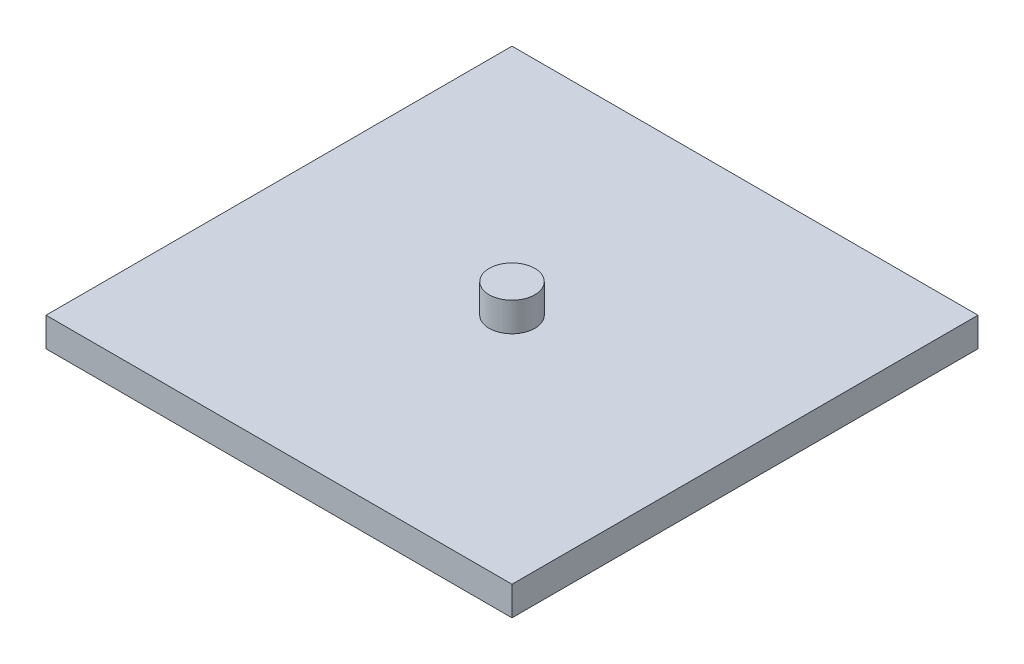
from build123d import *

# Parameters (mm, degrees)
SKETCH4_R           = 2.4892
BOSS_EXTRUDE1_DEPTH = 6.35
SKETCH6_W           = 50.8
SKETCH6_H           = 50.8
BOSS_EXTRUDE2_DEPTH = 3.175


with BuildPart() as part:
    # Sketch4 → Boss-Extrude1 (new body)
    with BuildSketch(Plane(origin=(0, -26.057660102, 0), x_dir=(1, 0, 0), z_dir=(0, 1, 0))):
        with Locations((-98.4954, 0)):
            Circle(SKETCH4_R)
    extrude(amount=BOSS_EXTRUDE1_DEPTH)

    # Sketch6 → Boss-Extrude2 (add)
    with BuildSketch(Plane(origin=(0, -26.057660102, 0), x_dir=(1, 0, 0), z_dir=(0, 1, 0))):
        with Locations((-98.4954, 0)):
            Rectangle(SKETCH6_W, SKETCH6_H)
    extrude(amount=BOSS_EXTRUDE2_DEPTH)


solid = part.part
